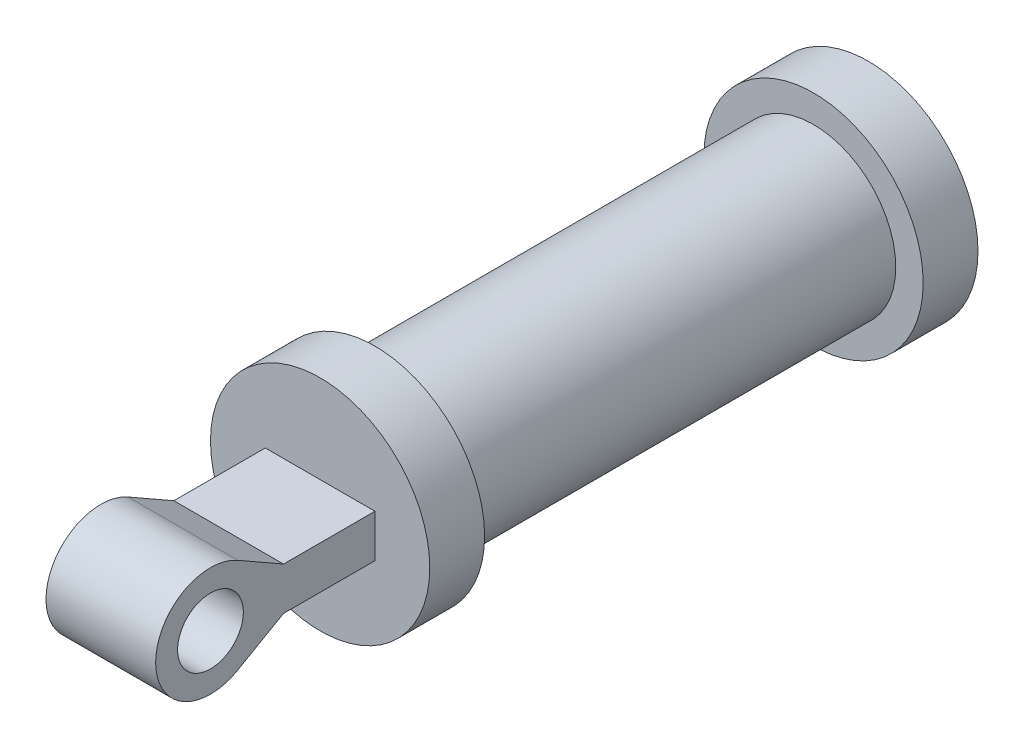
from build123d import *

# Parameters (mm, degrees)
SKETCH3_R           = 10
BOSS_EXTRUDE3_DEPTH = 5
SKETCH16_R          = 7.5
BOSS_EXTRUDE7_DEPTH = 40
SKETCH19_R          = 4
CUT_EXTRUDE3_DEPTH  = 40
SKETCH20_R          = 10
BOSS_EXTRUDE8_DEPTH = 5
SKETCH21_W          = 10.753504306
SKETCH21_H          = 13.699669868
BOSS_EXTRUDE9_DEPTH = 20
CUT_EXTRUDE5_DEPTH  = 16.376752153
SKETCH25_R          = 3
CUT_EXTRUDE6_DEPTH  = 16.376752153
CUT_EXTRUDE7_DEPTH  = 10
SKETCH28_W          = 0.376752153
SKETCH28_H          = 3.904338954
CUT_EXTRUDE8_DEPTH  = 8.338161
SCALE1_SCALE        = 10


with BuildPart() as part:
    # Sketch3 → Boss-Extrude3 (new body)
    with BuildSketch(Plane.XY):
        Circle(SKETCH3_R)
    extrude(amount=BOSS_EXTRUDE3_DEPTH)

    # Sketch14 → CBORE for M4 Cheese Head Screw1 (revolve, cut)
    with BuildSketch(Plane(origin=(0, 0, 5), x_dir=(0, -1, 0), z_dir=(1, 0, 0))):
        Polygon((0, 0), (0, 8.942065486), (2.4, 7.5), (2.4, 2.6), (4, 2.6), (4, 0.025), (4.025, 0), align=None)
    revolve(axis=Axis((0, 0, 11.35), (0, 0, -1)), mode=Mode.SUBTRACT)

    # Sketch16 → Boss-Extrude7 (add)
    with BuildSketch(Plane.XY.offset(5)):
        Circle(SKETCH16_R)
    extrude(amount=BOSS_EXTRUDE7_DEPTH)

    # Sketch19 → Cut-Extrude3 (cut)
    with BuildSketch(Plane.XY.offset(45)):
        Circle(SKETCH19_R)
    extrude(amount=-CUT_EXTRUDE3_DEPTH, mode=Mode.SUBTRACT)

    # Sketch20 → Boss-Extrude8 (add)
    with BuildSketch(Plane.XY.offset(45)):
        Circle(SKETCH20_R)
    extrude(amount=BOSS_EXTRUDE8_DEPTH)

    # Sketch21 → Boss-Extrude9 (add)
    with BuildSketch(Plane.XY.offset(50)):
        Rectangle(SKETCH21_W, SKETCH21_H)
    extrude(amount=BOSS_EXTRUDE9_DEPTH)

    # Sketch24 → Cut-Extrude5 (cut, through all)
    with BuildSketch(Plane(origin=(5.376752153, 0, 0), x_dir=(0, 0, -1), z_dir=(1, 0, 0))):
        with BuildLine():
            Line((-58.338160712, 1.952169477), (-50, 1.952169477))
            Line((-50, 1.952169477), (-50, 6.849834934))
            Line((-50, 6.849834934), (-70, 6.849834934))
            Line((-70, 6.849834934), (-70, 0))
            ThreePointArc((-70, 0), (-67.509703972, 4.324509912), (-62.51944561, 4.34129588))
            Line((-62.51944561, 4.34129588), (-58.338160712, 1.952169477))
        make_face()
        with BuildLine():
            Line((-50, -6.849834934), (-50, -1.952169477))
            Line((-50, -1.952169477), (-58.338160712, -1.952169477))
            Line((-58.338160712, -1.952169477), (-62.51944561, -4.34129588))
            ThreePointArc((-62.51944561, -4.34129588), (-67.509703972, -4.324509912), (-70, 0))
            Line((-70, 0), (-70, -6.849834934))
            Line((-70, -6.849834934), (-50, -6.849834934))
        make_face()
    extrude(amount=-CUT_EXTRUDE5_DEPTH, mode=Mode.SUBTRACT)

    # Sketch25 → Cut-Extrude6 (cut, through all)
    with BuildSketch(Plane(origin=(5.376752153, 0, 0), x_dir=(0, 0, -1), z_dir=(1, 0, 0))):
        with Locations((-65, 0)):
            Circle(SKETCH25_R)
    extrude(amount=-CUT_EXTRUDE6_DEPTH, mode=Mode.SUBTRACT)

    # Sketch27 → Cut-Extrude7 (cut, symmetric)
    with BuildSketch(Plane(origin=(0, 1.952169477, 0), x_dir=(1, 0, 0), z_dir=(0, 1, 0))):
        Polygon((5, -58.338160712), (5, -71.045531856), (7.637324511, -71.045531856), (7.637324511, -50), (5.376752153, -50), (5.376752153, -58.338160712), align=None)
        Polygon((-8.147357924, -71.045531856), (-5, -71.045531856), (-5, -58.338160712), (-5.376752153, -58.338160712), (-5.376752153, -50), (-8.147357924, -50), align=None)
    extrude(amount=CUT_EXTRUDE7_DEPTH, both=True, mode=Mode.SUBTRACT)

    # Sketch28 → Cut-Extrude8 (cut)
    with BuildSketch(Plane.XY.offset(58.338160712)):
        with Locations((-5.188376076, 0)):
            Rectangle(SKETCH28_W, SKETCH28_H)
        with Locations((5.188376076, 0)):
            Rectangle(SKETCH28_W, SKETCH28_H)
    extrude(amount=-CUT_EXTRUDE8_DEPTH, mode=Mode.SUBTRACT)


with BuildPart() as part_1:
    # Scale1: scaled about (0, 0, 29.145316633)
    add(part.part.scale(SCALE1_SCALE).moved(Location((0, 0, -262.307849697))))


solid = part_1.part
